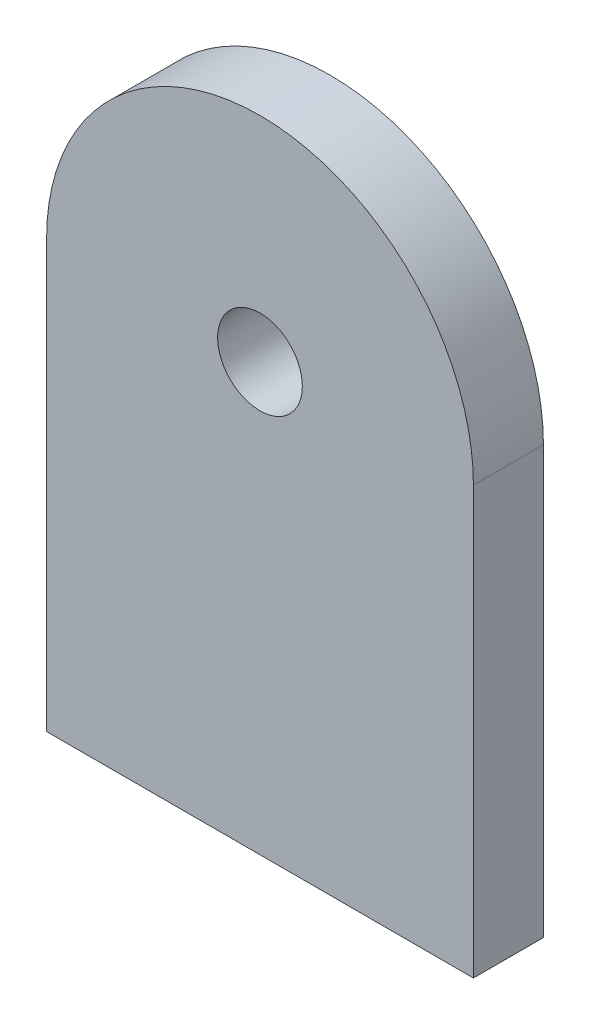
from build123d import *

# Parameters (mm, degrees)
SKETCH1_R           = 3.025
BOSS_EXTRUDE1_DEPTH = 2.5


with BuildPart() as part:
    # Sketch1 → Boss-Extrude1 (new body, symmetric)
    with BuildSketch(Plane.XY):
        with BuildLine():
            Line((-15.24, -30.48), (15.24, -30.48))
            Line((15.24, -30.48), (15.24, 0))
            ThreePointArc((15.24, 0), (0, 15.24), (-15.24, 0))
            Line((-15.24, 0), (-15.24, -30.48))
        make_face()
        Circle(SKETCH1_R, mode=Mode.SUBTRACT)
    extrude(amount=BOSS_EXTRUDE1_DEPTH, both=True)


solid = part.part
